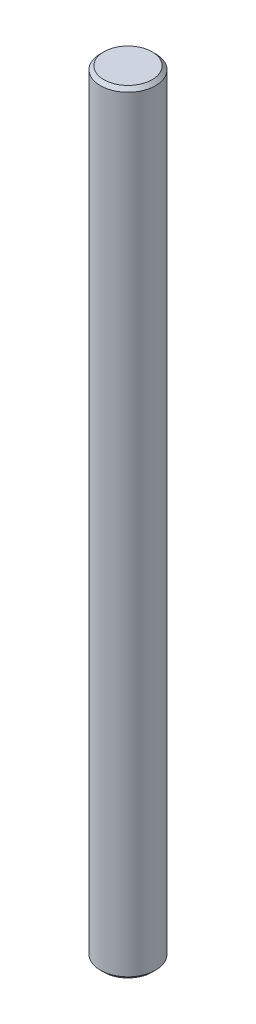
from build123d import *

# Parameters (mm, degrees)
SKETCH1_R           = 4
BOSS_EXTRUDE1_DEPTH = 112
CHAMFER1_SIZE       = 0.5


with BuildPart() as part:
    # Sketch1 → Boss-Extrude1 (new body)
    with BuildSketch(Plane(origin=(0, 0, 0), x_dir=(1, 0, 0), z_dir=(0, 1, 0))):
        Circle(SKETCH1_R)
    extrude(amount=BOSS_EXTRUDE1_DEPTH)

    # Chamfer1
    chamfer1_edges = [part.edges().sort_by_distance(p)[0] for p in [
        (-4, 0, 0),
        (-4, 112, 0),
    ]]
    chamfer(chamfer1_edges, length=CHAMFER1_SIZE)


solid = part.part
